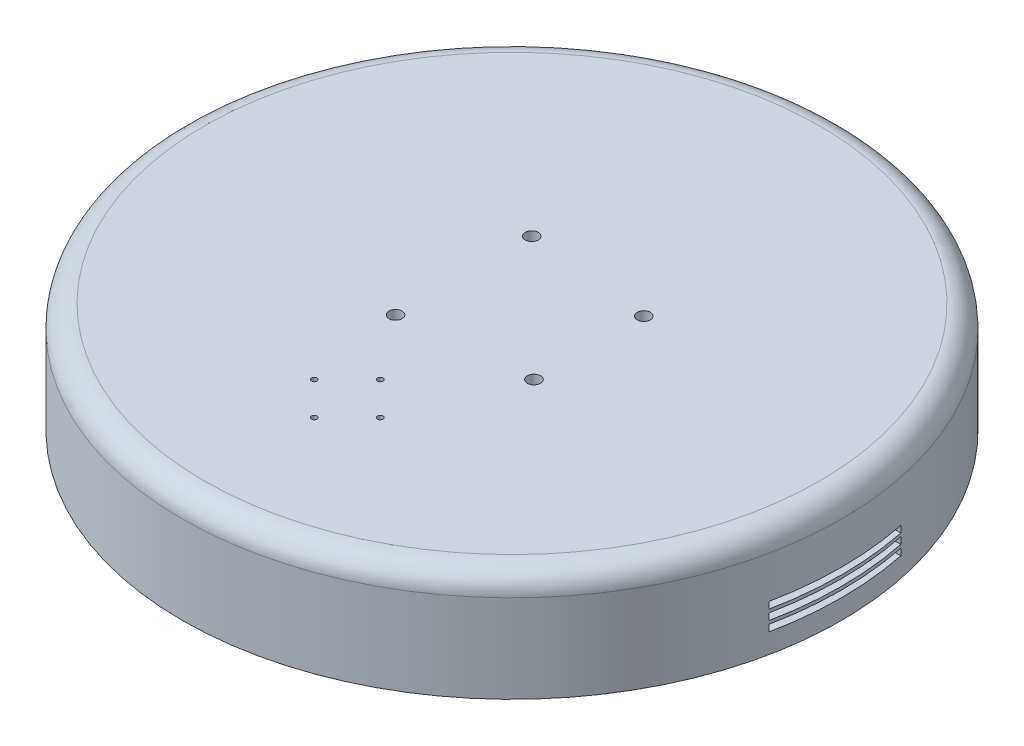
from build123d import *

# Parameters (mm, degrees)
SKETCH1_R               = 150
BOSS_EXTRUDE1_DEPTH     = 50
SHELL2_T                = -5
FILLET1_R               = 10
SKETCH4_R               = 3
SKETCH4_R_2             = 1.25
CUT_EXTRUDE2_DEPTH      = 218.944947177
CUT_EXTRUDE2_DEPTH_BACK = 218.944947177
SKETCH5_W               = 60
SKETCH5_H               = 3
CUT_EXTRUDE3_DEPTH      = 218.944947177
CUT_EXTRUDE3_DEPTH_BACK = 218.944947177


with BuildPart() as part:
    # Sketch1 → Boss-Extrude1 (new body)
    with BuildSketch(Plane(origin=(0, 0, 0), x_dir=(1, 0, 0), z_dir=(0, 1, 0))):
        with Locations(Location((0, 0, 0), (0, 0, 270))):
            Circle(SKETCH1_R)
    extrude(amount=BOSS_EXTRUDE1_DEPTH)

    # Shell2
    shell2_openings = [part.faces().sort_by_distance(p)[0] for p in [
        (0, 0, 0),
    ]]
    offset(amount=SHELL2_T, openings=shell2_openings, kind=Kind.INTERSECTION)

    # Fillet1
    fillet1_edges = [part.edges().sort_by_distance(p)[0] for p in [
        (0, 50, -150),
        (0, 45, -145),
    ]]
    fillet(fillet1_edges, radius=FILLET1_R)

    # Sketch4 → Cut-Extrude2 (cut, two sides)
    with BuildSketch(Plane(origin=(0, 50, 0), x_dir=(1, 0, 0), z_dir=(0, 1, 0))) as cut_extrude2_sk:
        with Locations(Location((-22, 31, 0), (0, 0, 270))):
            Circle(SKETCH4_R)
        with Locations(Location((35, 25, 0), (0, 0, 270))):
            Circle(SKETCH4_R)
        with Locations(Location((-22, -31, 0), (0, 0, 270))):
            Circle(SKETCH4_R)
        with Locations(Location((35, -25, 0), (0, 0, 270))):
            Circle(SKETCH4_R)
        with Locations(Location((0, -60, 0), (0, 0, 270))):
            Circle(SKETCH4_R_2)
        with Locations(Location((-15, -75, 0), (0, 0, 270))):
            Circle(SKETCH4_R_2)
        with Locations(Location((0, -90, 0), (0, 0, 270))):
            Circle(SKETCH4_R_2)
        with Locations(Location((15, -75, 0), (0, 0, 270))):
            Circle(SKETCH4_R_2)
    extrude(amount=CUT_EXTRUDE2_DEPTH, mode=Mode.SUBTRACT)
    extrude(cut_extrude2_sk.sketch, amount=-CUT_EXTRUDE2_DEPTH_BACK, mode=Mode.SUBTRACT)

    # Sketch5 → Cut-Extrude3 (cut, two sides)
    with BuildSketch(Plane(origin=(0, 0, 0), x_dir=(0, 0, -1), z_dir=(1, 0, 0))) as cut_extrude3_sk:
        with Locations((0, 15)):
            Rectangle(SKETCH5_W, SKETCH5_H)
        with Locations((0, 10.5)):
            Rectangle(SKETCH5_W, SKETCH5_H)
        with Locations((0, 19.5)):
            Rectangle(SKETCH5_W, SKETCH5_H)
    extrude(amount=CUT_EXTRUDE3_DEPTH, mode=Mode.SUBTRACT)
    extrude(cut_extrude3_sk.sketch, amount=-CUT_EXTRUDE3_DEPTH_BACK, mode=Mode.SUBTRACT)


solid = part.part
